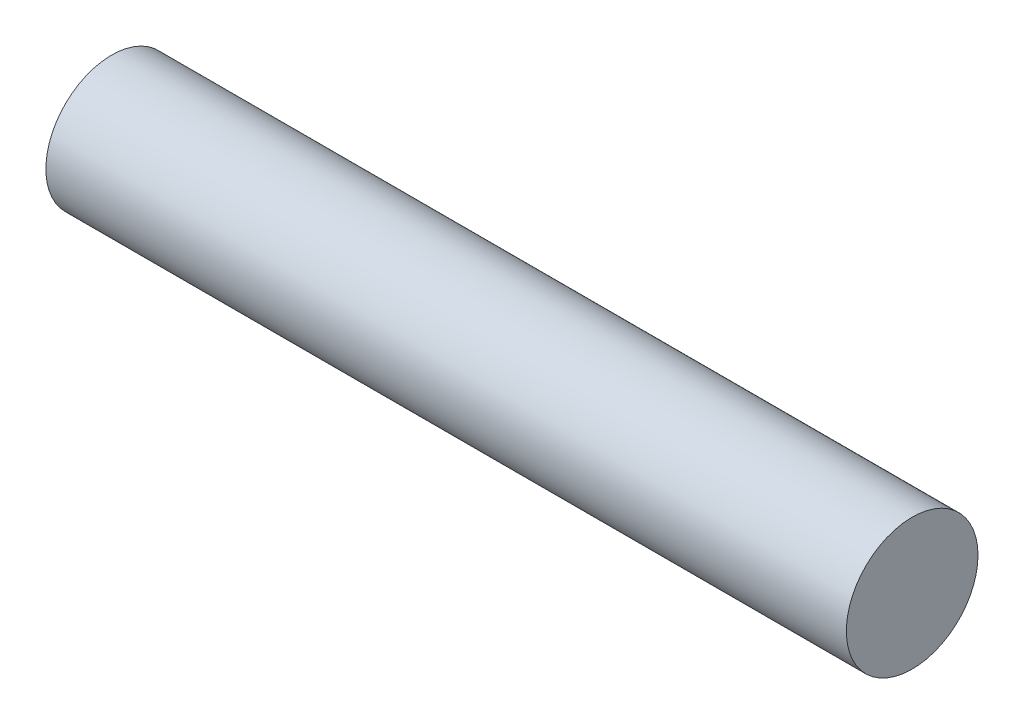
from build123d import *

# Parameters (mm, degrees)
SKETCH1_R           = 2.5
BOSS_EXTRUDE1_DEPTH = 30.4


with BuildPart() as part:
    # Sketch1 → Boss-Extrude1 (new body)
    with BuildSketch(Plane.YZ):
        Circle(SKETCH1_R)
    extrude(amount=BOSS_EXTRUDE1_DEPTH)


solid = part.part
